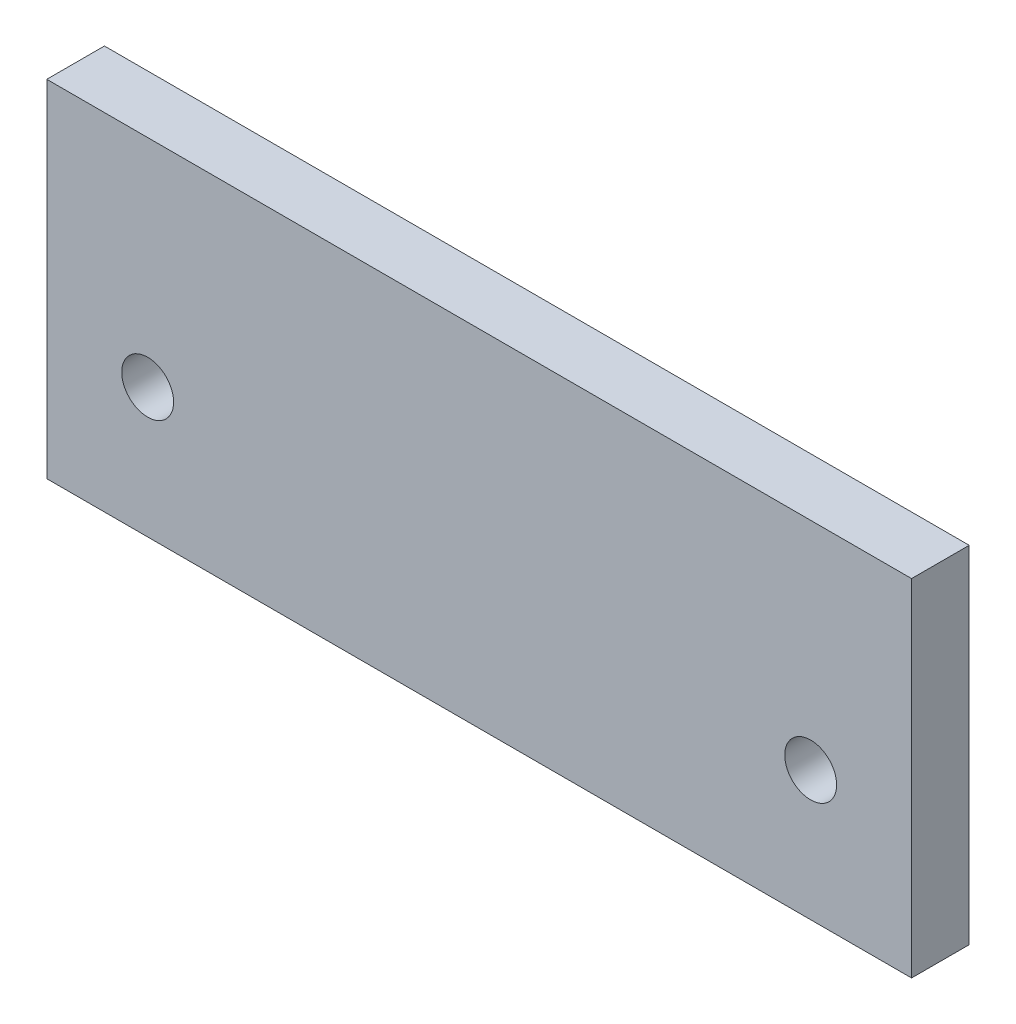
from build123d import *

# Parameters (mm, degrees)
SKETCH1_W           = 300
SKETCH1_H           = 120
BOSS_EXTRUDE1_DEPTH = 20
SKETCH2_R           = 9
CUT_EXTRUDE1_DEPTH  = 21


with BuildPart() as part:
    # Sketch1 → Boss-Extrude1 (new body)
    with BuildSketch(Plane.XY):
        with Locations((150, 60)):
            Rectangle(SKETCH1_W, SKETCH1_H)
    extrude(amount=BOSS_EXTRUDE1_DEPTH)

    # Sketch2 → Cut-Extrude1 (cut, through all)
    with BuildSketch(Plane.XY.offset(20)):
        with Locations((265, 45)):
            Circle(SKETCH2_R)
        with Locations((35, 45)):
            Circle(SKETCH2_R)
    extrude(amount=-CUT_EXTRUDE1_DEPTH, mode=Mode.SUBTRACT)


solid = part.part
